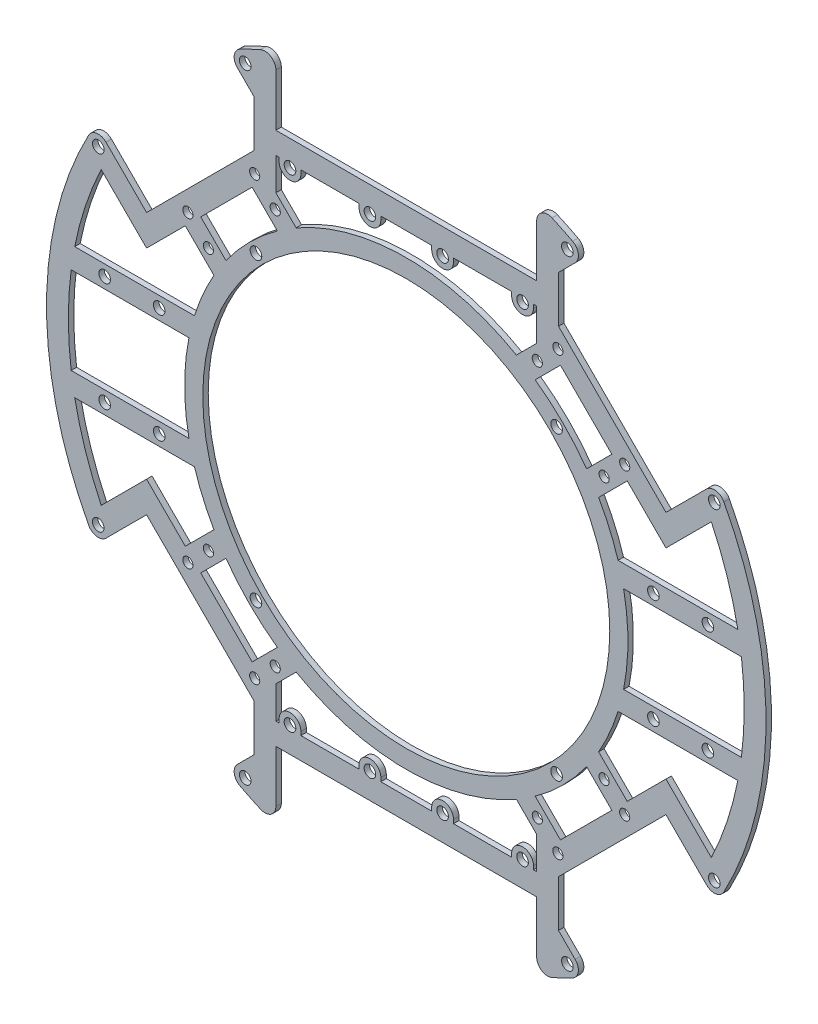
from build123d import *

# Parameters (mm, degrees)
SKETCH1_R           = 1.4
SKETCH1_R_2         = 1.6
SKETCH1_R_3         = 56
BOSS_EXTRUDE2_DEPTH = 1.5
BOSS_EXTRUDE3_DEPTH = 1.5
SKETCH3_R           = 1.6
CUT_EXTRUDE1_DEPTH  = 10
SKETCH4_R           = 1.6
BOSS_EXTRUDE4_DEPTH = 1.5
FILLET1_R           = 3
SKETCH5_R           = 1.6
BOSS_EXTRUDE5_DEPTH = 1.5
SKETCH6_R           = 1.6
CUT_EXTRUDE2_DEPTH  = 1.5
BOSS_EXTRUDE7_DEPTH = 1.5
SKETCH10_R          = 1.6
CUT_EXTRUDE3_DEPTH  = 1.5
SKETCH11_R          = 1.6
BOSS_EXTRUDE8_DEPTH = 1.5


with BuildPart() as part:
    # Sketch1 → Boss-Extrude2 (new body)
    with BuildSketch(Plane.XY):
        with BuildLine():
            Line((-35.888794811, 73.41211972), (-35.888794811, 92.265889727))
            ThreePointArc((-35.888794811, 92.265889727), (-42.061063674, 89.620683565), (-48.039811225, 86.563136135))
            Line((-48.039811225, 86.563136135), (-41.888794811, 80.41211972))
            Line((-41.888794811, 80.41211972), (-41.888794811, 65.59143593))
            Line((-41.888794811, 65.59143593), (-53.74011537, 53.74011537))
            Line((-53.74011537, 53.74011537), (-65.053823869, 42.426406871))
            Line((-65.053823869, 42.426406871), (-71.46564447, 36.01458627))
            Line((-71.46564447, 36.01458627), (-82.641648571, 47.190590371))
            ThreePointArc((-82.641648571, 47.190590371), (-85.206397148, 48.036317618), (-87.411811693, 46.477684716))
            ThreePointArc((-87.411811693, 46.477684716), (-99, 0), (-87.411811693, -46.477684716))
            ThreePointArc((-87.411811693, -46.477684716), (-85.206397148, -48.036317618), (-82.641648571, -47.190590371))
            Line((-82.641648571, -47.190590371), (-71.46564447, -36.01458627))
            Line((-71.46564447, -36.01458627), (-65.053823869, -42.426406871))
            Line((-65.053823869, -42.426406871), (-53.74011537, -53.74011537))
            Line((-53.74011537, -53.74011537), (-41.888794811, -65.59143593))
            Line((-41.888794811, -65.59143593), (-41.888794811, -80.41211972))
            Line((-41.888794811, -80.41211972), (-48.039811225, -86.563136135))
            ThreePointArc((-48.039811225, -86.563136135), (-42.061063674, -89.620683565), (-35.888794811, -92.265889727))
            Line((-35.888794811, -92.265889727), (-35.888794811, -73.41211972))
            Line((-35.888794811, -73.41211972), (35.888794811, -73.41211972))
            Line((35.888794811, -73.41211972), (35.888794811, -92.265889727))
            ThreePointArc((35.888794811, -92.265889727), (42.061063674, -89.620683565), (48.039811225, -86.563136135))
            Line((48.039811225, -86.563136135), (41.888794811, -80.41211972))
            Line((41.888794811, -80.41211972), (41.888794811, -65.59143593))
            Line((41.888794811, -65.59143593), (53.74011537, -53.74011537))
            Line((53.74011537, -53.74011537), (65.053823869, -42.426406871))
            Line((65.053823869, -42.426406871), (71.46564447, -36.01458627))
            Line((71.46564447, -36.01458627), (82.641648571, -47.190590371))
            ThreePointArc((82.641648571, -47.190590371), (85.206397148, -48.036317618), (87.411811693, -46.477684716))
            ThreePointArc((87.411811693, -46.477684716), (99, 0), (87.411811693, 46.477684716))
            ThreePointArc((87.411811693, 46.477684716), (85.206397148, 48.036317618), (82.641648571, 47.190590371))
            Line((82.641648571, 47.190590371), (71.46564447, 36.01458627))
            Line((71.46564447, 36.01458627), (65.053823869, 42.426406871))
            Line((65.053823869, 42.426406871), (53.74011537, 53.74011537))
            Line((53.74011537, 53.74011537), (41.888794811, 65.59143593))
            Line((41.888794811, 65.59143593), (41.888794811, 80.41211972))
            Line((41.888794811, 80.41211972), (48.039811225, 86.563136135))
            ThreePointArc((48.039811225, 86.563136135), (42.061063674, 89.620683565), (35.888794811, 92.265889727))
            Line((35.888794811, 92.265889727), (35.888794811, 73.41211972))
            Line((35.888794811, 73.41211972), (-35.888794811, 73.41211972))
        make_face()
        with Locations((-36.062445841, 54.447222151)):
            Circle(SKETCH1_R, mode=Mode.SUBTRACT)
        with Locations((-54.447222151, 36.062445841)):
            Circle(SKETCH1_R, mode=Mode.SUBTRACT)
        with Locations((-60.104076401, 41.71930009)):
            Circle(SKETCH1_R, mode=Mode.SUBTRACT)
        with Locations((-41.71930009, 60.104076401)):
            Circle(SKETCH1_R, mode=Mode.SUBTRACT)
        with Locations((41.365746699, 41.365746699)):
            Circle(SKETCH1_R_2, mode=Mode.SUBTRACT)
        with Locations((41.71930009, 60.104076401)):
            Circle(SKETCH1_R, mode=Mode.SUBTRACT)
        with Locations((60.104076401, 41.71930009)):
            Circle(SKETCH1_R, mode=Mode.SUBTRACT)
        with Locations((54.447222151, 36.062445841)):
            Circle(SKETCH1_R, mode=Mode.SUBTRACT)
        Circle(SKETCH1_R_3, mode=Mode.SUBTRACT)
        with Locations((36.062445841, 54.447222151)):
            Circle(SKETCH1_R, mode=Mode.SUBTRACT)
        with Locations((-40.571353127, 87.005547556)):
            Circle(SKETCH1_R_2, mode=Mode.SUBTRACT)
        with Locations((40.571353127, -87.005547556)):
            Circle(SKETCH1_R_2, mode=Mode.SUBTRACT)
        with Locations((-40.571353127, -87.005547556)):
            Circle(SKETCH1_R_2, mode=Mode.SUBTRACT)
        with Locations((41.365746699, -41.365746699)):
            Circle(SKETCH1_R_2, mode=Mode.SUBTRACT)
        with Locations((-41.365746699, 41.365746699)):
            Circle(SKETCH1_R_2, mode=Mode.SUBTRACT)
        with Locations((-84.762968914, 45.069270027)):
            Circle(SKETCH1_R_2, mode=Mode.SUBTRACT)
        with Locations((-41.365746699, -41.365746699)):
            Circle(SKETCH1_R_2, mode=Mode.SUBTRACT)
        with Locations((84.762968914, 45.069270027)):
            Circle(SKETCH1_R_2, mode=Mode.SUBTRACT)
        with Locations((40.571353127, 87.005547556)):
            Circle(SKETCH1_R_2, mode=Mode.SUBTRACT)
        with Locations((36.062445841, -54.447222151)):
            Circle(SKETCH1_R, mode=Mode.SUBTRACT)
        with Locations((54.447222151, -36.062445841)):
            Circle(SKETCH1_R, mode=Mode.SUBTRACT)
        with Locations((60.104076401, -41.71930009)):
            Circle(SKETCH1_R, mode=Mode.SUBTRACT)
        with Locations((41.71930009, -60.104076401)):
            Circle(SKETCH1_R, mode=Mode.SUBTRACT)
        with Locations((-41.71930009, -60.104076401)):
            Circle(SKETCH1_R, mode=Mode.SUBTRACT)
        with Locations((-60.104076401, -41.71930009)):
            Circle(SKETCH1_R, mode=Mode.SUBTRACT)
        with Locations((-54.447222151, -36.062445841)):
            Circle(SKETCH1_R, mode=Mode.SUBTRACT)
        with Locations((-36.062445841, -54.447222151)):
            Circle(SKETCH1_R, mode=Mode.SUBTRACT)
        with Locations((84.762968914, -45.069270027)):
            Circle(SKETCH1_R_2, mode=Mode.SUBTRACT)
        with Locations((-84.762968914, -45.069270027)):
            Circle(SKETCH1_R_2, mode=Mode.SUBTRACT)
        with BuildLine():
            Line((-56.568542495, 42.426406871), (-49.621038435, 35.478902811))
            ThreePointArc((-49.621038435, 35.478902811), (-43.133513652, 43.133513652), (-35.478902811, 49.621038435))
            Line((-35.478902811, 49.621038435), (-42.426406871, 56.568542495))
            Line((-42.426406871, 56.568542495), (-56.568542495, 42.426406871))
        make_face(mode=Mode.SUBTRACT)
        with BuildLine():
            Line((-57.337431152, 34.710014154), (-52.937019276, 30.309602278))
            ThreePointArc((-52.937019276, 30.309602278), (-61, 0), (-52.937019276, -30.309602278))
            Line((-52.937019276, -30.309602278), (-57.337431152, -34.710014154))
            Line((-57.337431152, -34.710014154), (-60.811183182, -38.183766184))
            Line((-60.811183182, -38.183766184), (-71.46564447, -27.529304896))
            Line((-71.46564447, -27.529304896), (-83.951228087, -40.014888513))
            ThreePointArc((-83.951228087, -40.014888513), (-93, 0), (-83.951228087, 40.014888513))
            Line((-83.951228087, 40.014888513), (-71.46564447, 27.529304896))
            Line((-71.46564447, 27.529304896), (-60.811183182, 38.183766184))
            Line((-60.811183182, 38.183766184), (-57.337431152, 34.710014154))
        make_face(mode=Mode.SUBTRACT)
        with BuildLine():
            Line((-35.888794811, 67.41211972), (-35.888794811, 58.516211808))
            Line((-35.888794811, 58.516211808), (-30.309602278, 52.937019275))
            ThreePointArc((-30.309602278, 52.937019275), (0, 61), (30.309602278, 52.937019275))
            Line((30.309602278, 52.937019275), (35.888794811, 58.516211808))
            Line((35.888794811, 58.516211808), (35.888794811, 67.41211972))
            Line((35.888794811, 67.41211972), (0, 67.41211972))
            Line((0, 67.41211972), (-35.888794811, 67.41211972))
        make_face(mode=Mode.SUBTRACT)
        with BuildLine():
            Line((60.811183182, 38.183766184), (71.46564447, 27.529304896))
            Line((71.46564447, 27.529304896), (83.951228087, 40.014888513))
            ThreePointArc((83.951228087, 40.014888513), (93, 0), (83.951228087, -40.014888513))
            Line((83.951228087, -40.014888513), (71.46564447, -27.529304896))
            Line((71.46564447, -27.529304896), (60.811183182, -38.183766184))
            Line((60.811183182, -38.183766184), (57.337431152, -34.710014154))
            Line((57.337431152, -34.710014154), (52.937019276, -30.309602278))
            ThreePointArc((52.937019276, -30.309602278), (61, 0), (52.937019276, 30.309602278))
            Line((52.937019276, 30.309602278), (57.337431152, 34.710014154))
            Line((57.337431152, 34.710014154), (60.811183182, 38.183766184))
        make_face(mode=Mode.SUBTRACT)
        with BuildLine():
            Line((42.426406871, 56.568542495), (56.568542495, 42.426406871))
            Line((56.568542495, 42.426406871), (49.621038435, 35.478902811))
            ThreePointArc((49.621038435, 35.478902811), (43.133513652, 43.133513652), (35.478902811, 49.621038435))
            Line((35.478902811, 49.621038435), (42.426406871, 56.568542495))
        make_face(mode=Mode.SUBTRACT)
        with BuildLine():
            Line((0, -67.41211972), (35.888794811, -67.41211972))
            Line((35.888794811, -67.41211972), (35.888794811, -58.516211808))
            Line((35.888794811, -58.516211808), (30.309602278, -52.937019275))
            ThreePointArc((30.309602278, -52.937019275), (0, -61), (-30.309602278, -52.937019275))
            Line((-30.309602278, -52.937019275), (-35.888794811, -58.516211808))
            Line((-35.888794811, -58.516211808), (-35.888794811, -67.41211972))
            Line((-35.888794811, -67.41211972), (0, -67.41211972))
        make_face(mode=Mode.SUBTRACT)
        with BuildLine():
            Line((56.568542495, -42.426406871), (49.621038435, -35.478902811))
            ThreePointArc((49.621038435, -35.478902811), (43.133513652, -43.133513652), (35.478902811, -49.621038435))
            Line((35.478902811, -49.621038435), (42.426406871, -56.568542495))
            Line((42.426406871, -56.568542495), (56.568542495, -42.426406871))
        make_face(mode=Mode.SUBTRACT)
        with BuildLine():
            Line((-42.426406871, -56.568542495), (-56.568542495, -42.426406871))
            Line((-56.568542495, -42.426406871), (-49.621038435, -35.478902811))
            ThreePointArc((-49.621038435, -35.478902811), (-43.133513652, -43.133513652), (-35.478902811, -49.621038435))
            Line((-35.478902811, -49.621038435), (-42.426406871, -56.568542495))
        make_face(mode=Mode.SUBTRACT)
    extrude(amount=BOSS_EXTRUDE2_DEPTH)

    # Sketch2 → Boss-Extrude3 (add)
    with BuildSketch(Plane.XY.offset(1.5)):
        with BuildLine():
            Line((-41.888794811, 80.41211972), (-41.888794811, 78.41211972))
            Line((-41.888794811, 78.41211972), (-49.31800671, 85.841331619))
            ThreePointArc((-49.31800671, 85.841331619), (-47.440229793, 86.893179233), (-45.540030314, 87.903956902))
            Line((-45.540030314, 87.903956902), (-41.888794811, 84.252721398))
            Line((-41.888794811, 84.252721398), (-41.888794811, 80.41211972))
        make_face()
        with BuildLine():
            Line((41.888794811, 84.252721398), (45.540030314, 87.903956902))
            ThreePointArc((45.540030314, 87.903956902), (47.440229793, 86.893179233), (49.31800671, 85.841331619))
            Line((49.31800671, 85.841331619), (41.888794811, 78.41211972))
            Line((41.888794811, 78.41211972), (41.888794811, 80.41211972))
            Line((41.888794811, 80.41211972), (41.888794811, 84.252721398))
        make_face()
        with BuildLine():
            Line((41.888794811, -80.41211972), (41.888794811, -78.41211972))
            Line((41.888794811, -78.41211972), (49.31800671, -85.841331619))
            ThreePointArc((49.31800671, -85.841331619), (47.440229793, -86.893179233), (45.540030314, -87.903956902))
            Line((45.540030314, -87.903956902), (41.888794811, -84.252721398))
            Line((41.888794811, -84.252721398), (41.888794811, -80.41211972))
        make_face()
        with BuildLine():
            Line((-41.888794811, -84.252721398), (-45.540030314, -87.903956902))
            ThreePointArc((-45.540030314, -87.903956902), (-47.440229793, -86.893179233), (-49.31800671, -85.841331619))
            Line((-49.31800671, -85.841331619), (-41.888794811, -78.41211972))
            Line((-41.888794811, -78.41211972), (-41.888794811, -80.41211972))
            Line((-41.888794811, -80.41211972), (-41.888794811, -84.252721398))
        make_face()
    extrude(amount=-BOSS_EXTRUDE3_DEPTH)

    # Sketch3 → Cut-Extrude1 (cut)
    with BuildSketch(Plane.XY.offset(1.5)):
        with Locations((-44.327866871, 85.153039985)):
            Circle(SKETCH3_R)
        with Locations((44.327866871, 85.153039985)):
            Circle(SKETCH3_R)
        with Locations((44.327866871, -85.153039985)):
            Circle(SKETCH3_R)
        with Locations((-44.327866871, -85.153039985)):
            Circle(SKETCH3_R)
    extrude(amount=-CUT_EXTRUDE1_DEPTH, mode=Mode.SUBTRACT)

    # Sketch4 → Boss-Extrude4 (add)
    with BuildSketch(Plane.XY.offset(1.5)):
        with Locations((-40.571353127, 87.005547556)):
            Circle(SKETCH4_R)
        with Locations((40.571353127, 87.005547556)):
            Circle(SKETCH4_R)
        with Locations((40.571353127, -87.005547556)):
            Circle(SKETCH4_R)
        with Locations((-40.571353127, -87.005547556)):
            Circle(SKETCH4_R)
    extrude(amount=-BOSS_EXTRUDE4_DEPTH)

    # Fillet1
    fillet1_edges = [part.edges().sort_by_distance(p)[0] for p in [
        (35.888794811, -92.265889727, 0.75),
        (-35.888794811, -92.265889727, 0.75),
        (-35.888794811, 92.265889727, 0.75),
        (35.888794811, 92.265889727, 0.75),
        (49.31800671, 85.841331619, 0.75),
        (-49.31800671, 85.841331619, 0.75),
        (49.31800671, -85.841331619, 0.75),
        (-49.31800671, -85.841331619, 0.75),
    ]]
    fillet(fillet1_edges, radius=FILLET1_R)

    # Sketch5 → Boss-Extrude5 (add)
    with BuildSketch(Plane.XY.offset(1.5)):
        with BuildLine():
            ThreePointArc((-7, 66.41211972), (-10, 63.41211972), (-13, 66.41211972))
            Line((-13, 66.41211972), (-13, 67.41211972))
            Line((-13, 67.41211972), (-9.775161328, 70.187281048))
            Line((-9.775161328, 70.187281048), (-7, 67.41211972))
            Line((-7, 67.41211972), (-7, 66.41211972))
        make_face()
        with Locations((-10, 66.41211972)):
            Circle(SKETCH5_R, mode=Mode.SUBTRACT)
        with BuildLine():
            Line((7, 66.41211972), (7, 67.41211972))
            Line((7, 67.41211972), (9.775161328, 70.187281048))
            Line((9.775161328, 70.187281048), (13, 67.41211972))
            Line((13, 67.41211972), (13, 66.41211972))
            ThreePointArc((13, 66.41211972), (10, 63.41211972), (7, 66.41211972))
        make_face()
        with Locations((10, 66.41211972)):
            Circle(SKETCH5_R, mode=Mode.SUBTRACT)
        with BuildLine():
            ThreePointArc((7, -66.41211972), (10, -63.41211972), (13, -66.41211972))
            Line((13, -66.41211972), (13, -67.41211972))
            Line((13, -67.41211972), (9.775161328, -70.187281048))
            Line((9.775161328, -70.187281048), (7, -67.41211972))
            Line((7, -67.41211972), (7, -66.41211972))
        make_face()
        with Locations((10, -66.41211972)):
            Circle(SKETCH5_R, mode=Mode.SUBTRACT)
        with BuildLine():
            Line((-7, -66.41211972), (-7, -67.41211972))
            Line((-7, -67.41211972), (-9.775161328, -70.187281048))
            Line((-9.775161328, -70.187281048), (-13, -67.41211972))
            Line((-13, -67.41211972), (-13, -66.41211972))
            ThreePointArc((-13, -66.41211972), (-10, -63.41211972), (-7, -66.41211972))
        make_face()
        with Locations((-10, -66.41211972)):
            Circle(SKETCH5_R, mode=Mode.SUBTRACT)
    extrude(amount=-BOSS_EXTRUDE5_DEPTH)

    # Sketch6 → Cut-Extrude2 (cut)
    with BuildSketch(Plane.XY.offset(1.5)):
        with Locations((-10, -66.41211972)):
            Circle(SKETCH6_R)
        with Locations((10, -66.41211972)):
            Circle(SKETCH6_R)
        with Locations((10, 66.41211972)):
            Circle(SKETCH6_R)
        with Locations((-10, 66.41211972)):
            Circle(SKETCH6_R)
    extrude(amount=-CUT_EXTRUDE2_DEPTH, mode=Mode.SUBTRACT)

    # Sketch9 → Boss-Extrude7 (add)
    with BuildSketch(Plane.XY.offset(1.5)):
        with BuildLine():
            Line((30.7510004, 67.41211972), (29, 67.41211972))
            Line((29, 67.41211972), (29, 66.41211972))
            ThreePointArc((29, 66.41211972), (32, 63.41211972), (35, 66.41211972))
            Line((35, 66.41211972), (35, 67.41211972))
            Line((35, 67.41211972), (33.2489996, 67.41211972))
            ThreePointArc((33.2489996, 67.41211972), (32, 64.81211972), (30.7510004, 67.41211972))
        make_face()
        with BuildLine():
            Line((-35, 67.41211972), (-35, 66.41211972))
            ThreePointArc((-35, 66.41211972), (-32, 63.41211972), (-29, 66.41211972))
            Line((-29, 66.41211972), (-29, 67.41211972))
            Line((-29, 67.41211972), (-30.7510004, 67.41211972))
            ThreePointArc((-30.7510004, 67.41211972), (-32, 64.81211972), (-33.2489996, 67.41211972))
            Line((-33.2489996, 67.41211972), (-35, 67.41211972))
        make_face()
        with BuildLine():
            Line((-30.7510004, -67.41211972), (-29, -67.41211972))
            Line((-29, -67.41211972), (-29, -66.41211972))
            ThreePointArc((-29, -66.41211972), (-32, -63.41211972), (-35, -66.41211972))
            Line((-35, -66.41211972), (-35, -67.41211972))
            Line((-35, -67.41211972), (-33.2489996, -67.41211972))
            ThreePointArc((-33.2489996, -67.41211972), (-32, -64.81211972), (-30.7510004, -67.41211972))
        make_face()
        with BuildLine():
            Line((35, -67.41211972), (35, -66.41211972))
            ThreePointArc((35, -66.41211972), (32, -63.41211972), (29, -66.41211972))
            Line((29, -66.41211972), (29, -67.41211972))
            Line((29, -67.41211972), (30.7510004, -67.41211972))
            ThreePointArc((30.7510004, -67.41211972), (32, -64.81211972), (33.2489996, -67.41211972))
            Line((33.2489996, -67.41211972), (35, -67.41211972))
        make_face()
    extrude(amount=-BOSS_EXTRUDE7_DEPTH)

    # Sketch10 → Cut-Extrude3 (cut)
    with BuildSketch(Plane.XY.offset(1.5)):
        with Locations((-32, 66.41211972)):
            Circle(SKETCH10_R)
        with Locations((32, 66.41211972)):
            Circle(SKETCH10_R)
        with Locations((32, -66.41211972)):
            Circle(SKETCH10_R)
        with Locations((-32, -66.41211972)):
            Circle(SKETCH10_R)
    extrude(amount=-CUT_EXTRUDE3_DEPTH, mode=Mode.SUBTRACT)

    # Sketch11 → Boss-Extrude8 (add)
    with BuildSketch(Plane.XY.offset(1.5)):
        Polygon((-93, 15), (-93, 12), (-56.493838874, 12), (-56.493838874, 18), (-83, 18), (-91.241437954, 18), (-93, 18), align=None)
        with Locations((-83, 15)):
            Circle(SKETCH11_R, mode=Mode.SUBTRACT)
        with Locations((-68, 15)):
            Circle(SKETCH11_R, mode=Mode.SUBTRACT)
        Polygon((-83, -18), (-91.241437954, -18), (-93, -18), (-93, -12), (-56.493838874, -12), (-56.493838874, -18), align=None)
        with Locations((-68, -15)):
            Circle(SKETCH11_R, mode=Mode.SUBTRACT)
        with Locations((-83, -15)):
            Circle(SKETCH11_R, mode=Mode.SUBTRACT)
        Polygon((83, 18), (91.241437954, 18), (93, 18), (93, 12), (56.493838874, 12), (56.493838874, 18), align=None)
        with Locations((68, 15)):
            Circle(SKETCH11_R, mode=Mode.SUBTRACT)
        with Locations((83, 15)):
            Circle(SKETCH11_R, mode=Mode.SUBTRACT)
        Polygon((93, -15), (93, -12), (56.493838874, -12), (56.493838874, -18), (83, -18), (91.241437954, -18), (93, -18), align=None)
        with Locations((68, -15)):
            Circle(SKETCH11_R, mode=Mode.SUBTRACT)
        with Locations((83, -15)):
            Circle(SKETCH11_R, mode=Mode.SUBTRACT)
    extrude(amount=-BOSS_EXTRUDE8_DEPTH)


solid = part.part
